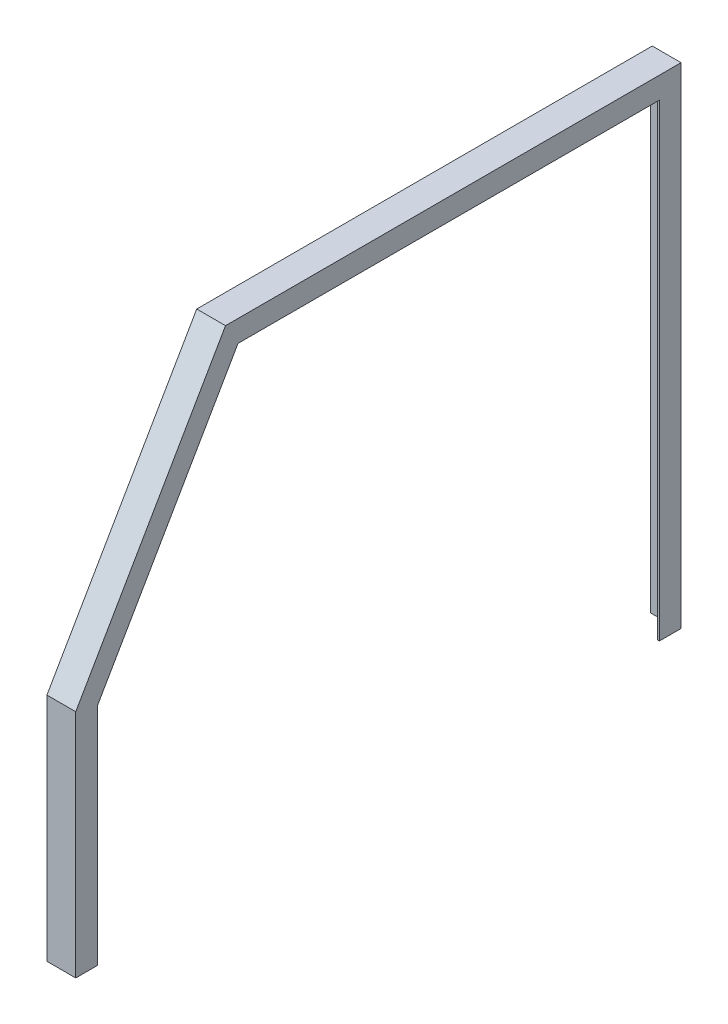
from build123d import *

# Parameters (mm, degrees)
BOSS_EXTRUDE1_DEPTH = 3.175
BOSS_EXTRUDE2_DEPTH = 47.625


with BuildPart() as part:
    # Sketch1 → Boss-Extrude1 (new body)
    with BuildSketch(Plane(origin=(0, 0, 0), x_dir=(0, 0, -1), z_dir=(1, 0, 0))):
        Polygon((-495.3, 0), (-495.3, 396.191135768), (-247.43841167, 825.5), (495.3, 825.5), (495.3, 0), (533.4, 0), (533.4, 863.6), (-269.435456927, 863.6), (-533.4, 406.4), (-533.4, 0), align=None)
    extrude(amount=BOSS_EXTRUDE1_DEPTH)

    # Sketch2 → Boss-Extrude2 (add)
    with BuildSketch(Plane.ZY):
        Polygon((530.225, 0), (530.225, 405.549261314), (267.602369822, 860.425), (-530.225, 860.425), (-530.225, 0), (-533.4, 0), (-533.4, 863.6), (269.435456927, 863.6), (533.4, 406.4), (533.4, 0), align=None)
    extrude(amount=BOSS_EXTRUDE2_DEPTH)


solid = part.part
